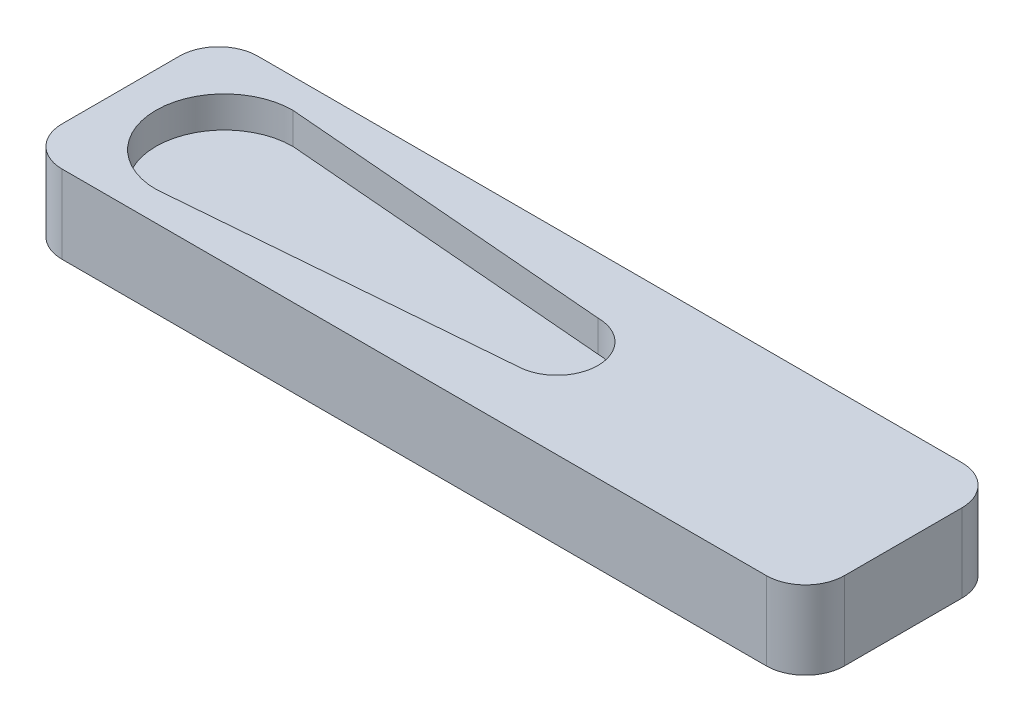
from build123d import *

# Parameters (mm, degrees)
SKETCH_1_W          = 40
SKETCH_1_H          = 10
EXTRUDE_1_DEPTH     = 4
CUT_EXTRUDE_1_DEPTH = 1.6
FILLET_1_R          = 2


with BuildPart() as part:
    # 스케치1 → 보스-돌출1 (new body)
    with BuildSketch(Plane(origin=(0, 0, 0), x_dir=(1, 0, 0), z_dir=(0, 1, 0))):
        Rectangle(SKETCH_1_W, SKETCH_1_H)
    extrude(amount=EXTRUDE_1_DEPTH)

    # 스케치2 → 컷-돌출1 (cut)
    with BuildSketch(Plane(origin=(0, 4, 0), x_dir=(1, 0, 0), z_dir=(0, 1, 0))):
        with BuildLine():
            Line((-14.703333421, -3.5), (2.296666579, -2.1))
            ThreePointArc((2.296666579, -2.1), (4.396666579, 0), (2.296666579, 2.1))
            Line((2.296666579, 2.1), (-14.703333421, 3.5))
            ThreePointArc((-14.703333421, 3.5), (-18.203333421, 0), (-14.703333421, -3.5))
        make_face()
    extrude(amount=-CUT_EXTRUDE_1_DEPTH, mode=Mode.SUBTRACT)

    # 필렛1
    fillet_1_edges = [part.edges().sort_by_distance(p)[0] for p in [
        (20, 2, 5),
        (-20, 2, 5),
        (-20, 2, -5),
        (20, 2, -5),
    ]]
    fillet(fillet_1_edges, radius=FILLET_1_R)


solid = part.part
